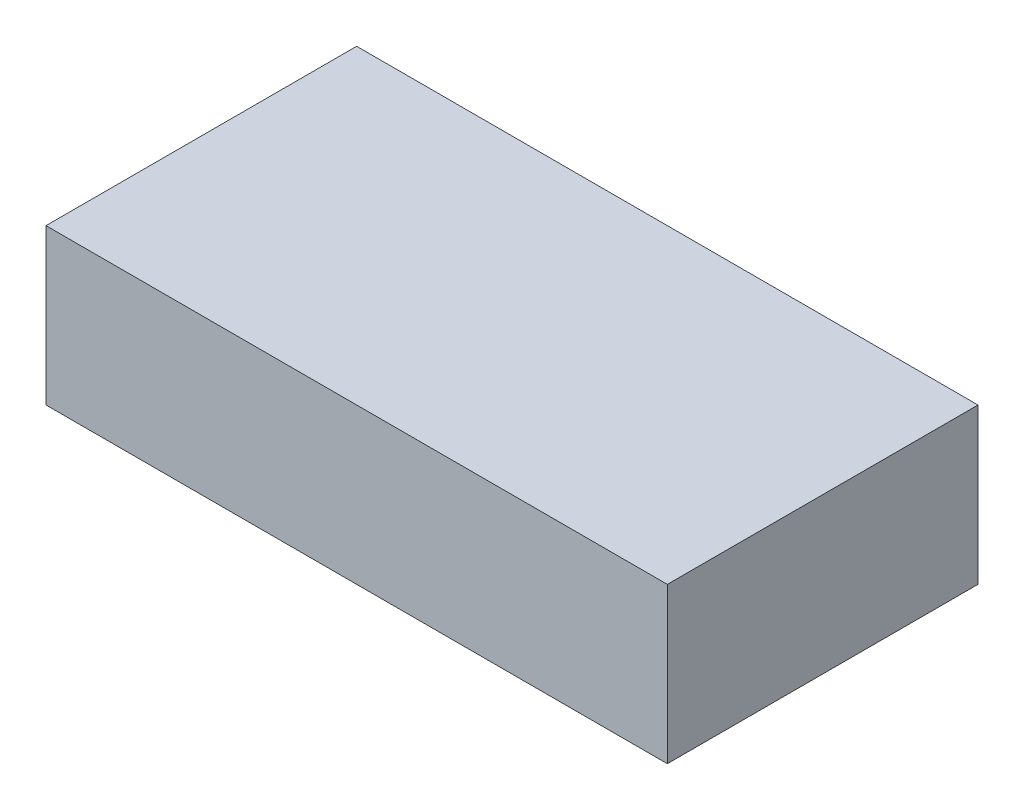
from build123d import *

# Parameters (mm, degrees)
SKETCH1_W           = 4
SKETCH1_H           = 2
BOSS_EXTRUDE1_DEPTH = 1


with BuildPart() as part:
    # Sketch1 → Boss-Extrude1 (new body)
    with BuildSketch(Plane(origin=(0, 0, 0), x_dir=(1, 0, 0), z_dir=(0, 1, 0))):
        with Locations((2, 1)):
            Rectangle(SKETCH1_W, SKETCH1_H)
    extrude(amount=BOSS_EXTRUDE1_DEPTH)


solid = part.part
